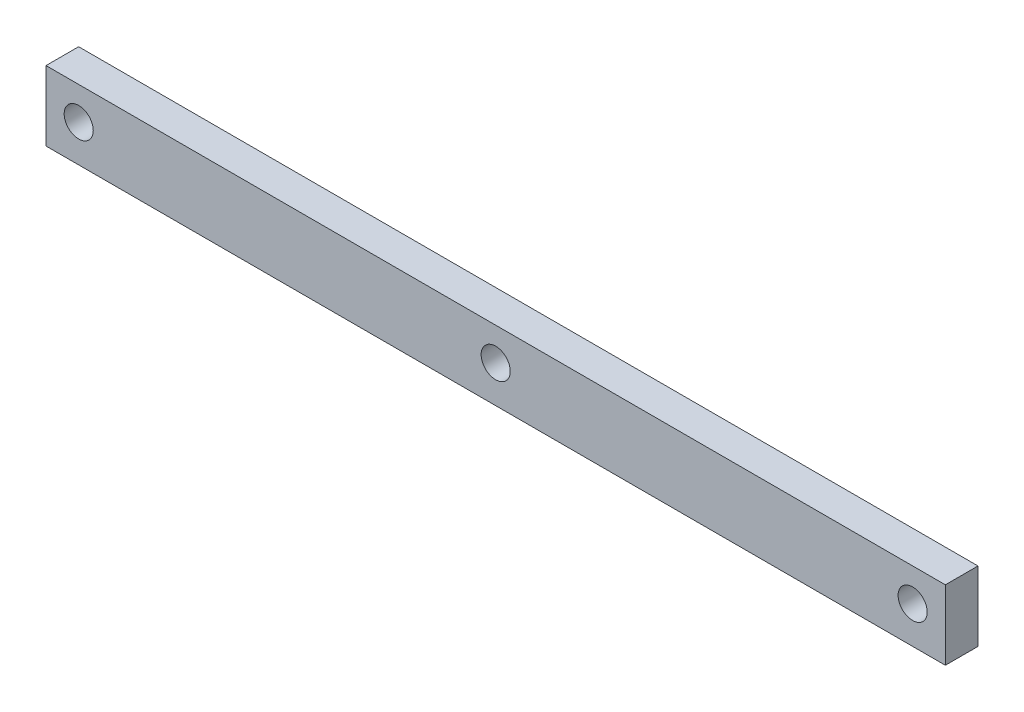
from build123d import *

# Parameters (mm, degrees)
SKETCH1_W           = 87.47
SKETCH1_H           = 9.7
BOSS_EXTRUDE1_DEPTH = 3.175
SKETCH3_R           = 1.415
CUT_EXTRUDE1_DEPTH  = 10
CUT_EXTRUDE2_DEPTH  = 10


with BuildPart() as part:
    # Sketch1 → Boss-Extrude1 (new body)
    with BuildSketch(Plane.XY):
        Rectangle(SKETCH1_W, SKETCH1_H)
    extrude(amount=BOSS_EXTRUDE1_DEPTH)

    # Sketch3 → Cut-Extrude1 (cut)
    with BuildSketch(Plane.XY.offset(3.175)):
        with Locations((-40.553019485, 1.668019485)):
            Circle(SKETCH3_R)
        with Locations((0, 1.668019485)):
            Circle(SKETCH3_R)
        with Locations((40.553019485, 1.668019485)):
            Circle(SKETCH3_R)
    extrude(amount=-CUT_EXTRUDE1_DEPTH, mode=Mode.SUBTRACT)

    # Sketch4 → Cut-Extrude2 (cut)
    with BuildSketch(Plane.XY.offset(3.175)):
        Polygon((0, -1.93), (-43.735, -1.93), (-43.735, -4.85), (43.735, -4.85), (43.735, -1.93), align=None)
    extrude(amount=-CUT_EXTRUDE2_DEPTH, mode=Mode.SUBTRACT)


solid = part.part
